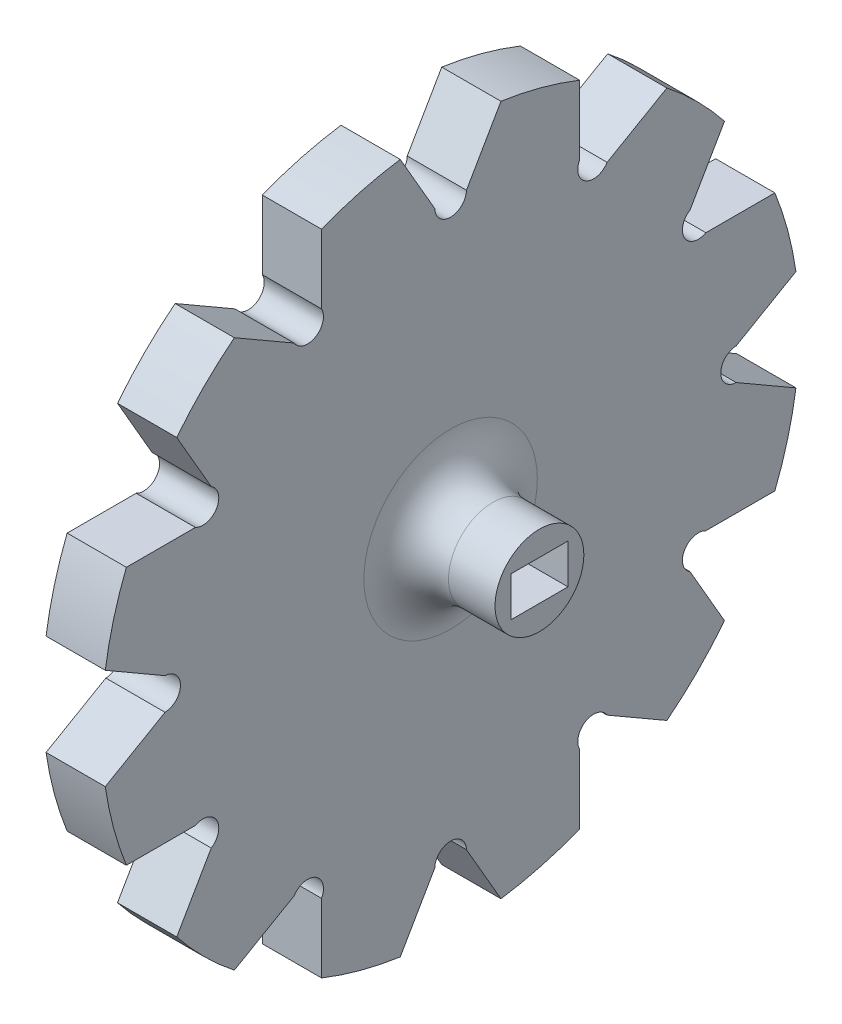
from build123d import *

# Parameters (mm, degrees)
SKETCH3_R           = 27.045923136
BOSS_EXTRUDE1_DEPTH = 5.6
SKETCH4_R           = 1.5
CUT_EXTRUDE1_DEPTH  = 6.6
BOSS_EXTRUDE3_DEPTH = 5.6
SKETCH6_R           = 4.2
BOSS_EXTRUDE4_DEPTH = 8.4
SKETCH7_W           = 5.4
SKETCH7_H           = 3.76
CUT_EXTRUDE2_DEPTH  = 6
FILLET1_R           = 4


with BuildPart() as part:
    # Sketch3 → Boss-Extrude1 (new body)
    with BuildSketch(Plane(origin=(0, 0, 0), x_dir=(0, 0, -1), z_dir=(1, 0, 0))):
        Circle(SKETCH3_R)
    extrude(amount=BOSS_EXTRUDE1_DEPTH)

    # Sketch4 → Cut-Extrude1 (cut, through all)
    with BuildSketch(Plane(origin=(5.6, 0, 0), x_dir=(0, 0, -1), z_dir=(1, 0, 0))):
        with Locations((0, 27.045923136)):
            Circle(SKETCH4_R)
        with Locations((13.522961568, 23.422456505)):
            Circle(SKETCH4_R)
        with Locations((23.422456505, 13.522961568)):
            Circle(SKETCH4_R)
        with Locations((27.045923136, 0)):
            Circle(SKETCH4_R)
        with Locations((23.422456505, -13.522961568)):
            Circle(SKETCH4_R)
        with Locations((13.522961568, -23.422456505)):
            Circle(SKETCH4_R)
        with Locations((0, -27.045923136)):
            Circle(SKETCH4_R)
        with Locations((-13.522961568, -23.422456505)):
            Circle(SKETCH4_R)
        with Locations((-23.422456505, -13.522961568)):
            Circle(SKETCH4_R)
        with Locations((-27.045923136, 0)):
            Circle(SKETCH4_R)
        with Locations((-23.422456505, 13.522961568)):
            Circle(SKETCH4_R)
        with Locations((-13.522961568, 23.422456505)):
            Circle(SKETCH4_R)
    extrude(amount=-CUT_EXTRUDE1_DEPTH, mode=Mode.SUBTRACT)

    # Sketch5 → Boss-Extrude3 (add)
    with BuildSketch(Plane(origin=(5.6, 0, 0), x_dir=(0, 0, -1), z_dir=(1, 0, 0))):
        with BuildLine():
            Line((1.499423149, 27.004327218), (4.76164368, 32.654658924))
            ThreePointArc((4.76164368, 32.654658924), (8.541028488, 31.875552268), (12.203625071, 30.660586021))
            Line((12.203625071, 30.660586021), (12.203625071, 24.136144957))
            Line((12.203625071, 24.136144957), (2.679491924, 10))
            Line((2.679491924, 10), (1.499423149, 27.004327218))
        make_face()
        with BuildLine():
            Line((22.636721809, 14.800702147), (7.320508076, 7.320508076))
            Line((7.320508076, 7.320508076), (14.800702147, 22.636721809))
            Line((14.800702147, 22.636721809), (20.451033853, 25.89894234))
            ThreePointArc((20.451033853, 25.89894234), (23.334523779, 23.334523779), (25.89894234, 20.451033853))
            Line((25.89894234, 20.451033853), (22.636721809, 14.800702147))
        make_face()
        with BuildLine():
            Line((27.004327218, 1.499423149), (10, 2.679491924))
            Line((10, 2.679491924), (24.136144957, 12.203625071))
            Line((24.136144957, 12.203625071), (30.660586021, 12.203625071))
            ThreePointArc((30.660586021, 12.203625071), (31.875552268, 8.541028488), (32.654658924, 4.76164368))
            Line((32.654658924, 4.76164368), (27.004327218, 1.499423149))
        make_face()
        with BuildLine():
            Line((24.136144957, -12.203625071), (10, -2.679491924))
            Line((10, -2.679491924), (27.004327218, -1.499423149))
            Line((27.004327218, -1.499423149), (32.654658924, -4.76164368))
            ThreePointArc((32.654658924, -4.76164368), (31.875552268, -8.541028488), (30.660586021, -12.203625071))
            Line((30.660586021, -12.203625071), (24.136144957, -12.203625071))
        make_face()
        with BuildLine():
            Line((14.800702147, -22.636721809), (7.320508076, -7.320508076))
            Line((7.320508076, -7.320508076), (22.636721809, -14.800702147))
            Line((22.636721809, -14.800702147), (25.89894234, -20.451033853))
            ThreePointArc((25.89894234, -20.451033853), (23.334523779, -23.334523779), (20.451033853, -25.89894234))
            Line((20.451033853, -25.89894234), (14.800702147, -22.636721809))
        make_face()
        with BuildLine():
            Line((1.499423149, -27.004327218), (2.679491924, -10))
            Line((2.679491924, -10), (12.203625071, -24.136144957))
            Line((12.203625071, -24.136144957), (12.203625071, -30.660586021))
            ThreePointArc((12.203625071, -30.660586021), (8.541028488, -31.875552268), (4.76164368, -32.654658924))
            Line((4.76164368, -32.654658924), (1.499423149, -27.004327218))
        make_face()
        with BuildLine():
            Line((-12.203625071, -24.136144957), (-2.679491924, -10))
            Line((-2.679491924, -10), (-1.499423149, -27.004327218))
            Line((-1.499423149, -27.004327218), (-4.76164368, -32.654658924))
            ThreePointArc((-4.76164368, -32.654658924), (-8.541028488, -31.875552268), (-12.203625071, -30.660586021))
            Line((-12.203625071, -30.660586021), (-12.203625071, -24.136144957))
        make_face()
        with BuildLine():
            Line((-22.636721809, -14.800702147), (-7.320508076, -7.320508076))
            Line((-7.320508076, -7.320508076), (-14.800702147, -22.636721809))
            Line((-14.800702147, -22.636721809), (-20.451033853, -25.89894234))
            ThreePointArc((-20.451033853, -25.89894234), (-23.334523779, -23.334523779), (-25.89894234, -20.451033853))
            Line((-25.89894234, -20.451033853), (-22.636721809, -14.800702147))
        make_face()
        with BuildLine():
            Line((-27.004327218, -1.499423149), (-10, -2.679491924))
            Line((-10, -2.679491924), (-24.136144957, -12.203625071))
            Line((-24.136144957, -12.203625071), (-30.660586021, -12.203625071))
            ThreePointArc((-30.660586021, -12.203625071), (-31.875552268, -8.541028488), (-32.654658924, -4.76164368))
            Line((-32.654658924, -4.76164368), (-27.004327218, -1.499423149))
        make_face()
        with BuildLine():
            Line((-24.136144957, 12.203625071), (-10, 2.679491924))
            Line((-10, 2.679491924), (-27.004327218, 1.499423149))
            Line((-27.004327218, 1.499423149), (-32.654658924, 4.76164368))
            ThreePointArc((-32.654658924, 4.76164368), (-31.875552268, 8.541028488), (-30.660586021, 12.203625071))
            Line((-30.660586021, 12.203625071), (-24.136144957, 12.203625071))
        make_face()
        with BuildLine():
            Line((-14.800702147, 22.636721809), (-7.320508076, 7.320508076))
            Line((-7.320508076, 7.320508076), (-22.636721809, 14.800702147))
            Line((-22.636721809, 14.800702147), (-25.89894234, 20.451033853))
            ThreePointArc((-25.89894234, 20.451033853), (-23.334523779, 23.334523779), (-20.451033853, 25.89894234))
            Line((-20.451033853, 25.89894234), (-14.800702147, 22.636721809))
        make_face()
        with BuildLine():
            Line((-1.499423149, 27.004327218), (-2.679491924, 10))
            Line((-2.679491924, 10), (-12.203625071, 24.136144957))
            Line((-12.203625071, 24.136144957), (-12.203625071, 30.660586021))
            ThreePointArc((-12.203625071, 30.660586021), (-8.541028488, 31.875552268), (-4.76164368, 32.654658924))
            Line((-4.76164368, 32.654658924), (-1.499423149, 27.004327218))
        make_face()
    extrude(amount=-BOSS_EXTRUDE3_DEPTH)

    # Sketch6 → Boss-Extrude4 (add)
    with BuildSketch(Plane(origin=(5.6, 0, 0), x_dir=(0, 0, -1), z_dir=(1, 0, 0))):
        Circle(SKETCH6_R)
    extrude(amount=BOSS_EXTRUDE4_DEPTH)

    # Sketch7 → Cut-Extrude2 (cut)
    with BuildSketch(Plane(origin=(14, 0, 0), x_dir=(0, 0, -1), z_dir=(1, 0, 0))):
        Rectangle(SKETCH7_W, SKETCH7_H)
    extrude(amount=-CUT_EXTRUDE2_DEPTH, mode=Mode.SUBTRACT)

    # Fillet1
    fillet1_edges = [part.edges().sort_by_distance(p)[0] for p in [
        (5.6, 0, 4.2),
    ]]
    fillet(fillet1_edges, radius=FILLET1_R)


solid = part.part
